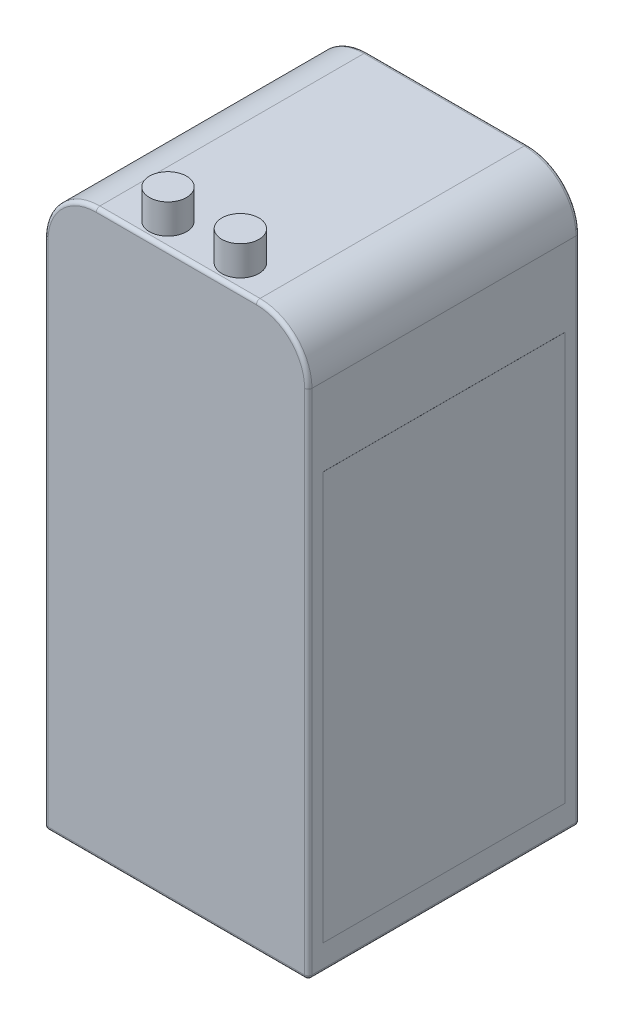
from build123d import *

# Parameters (mm, degrees)
SKETCH1_W             = 35.6
SKETCH1_H             = 36.6
BOSS_EXTRUDE1_DEPTH   = 76
SKETCH2_R             = 2.5
BOSS_EXTRUDE2_DEPTH   = 4
BOSS_EXTRUDE2_2_DEPTH = 4
FILLET1_R             = 7
FILLET2_R             = 0.5
SKETCH3_W             = 32.6
SKETCH3_H             = 55
BOSS_EXTRUDE3_DEPTH   = 0.01


with BuildPart() as part:
    # Sketch1 → Boss-Extrude1 (new body)
    with BuildSketch(Plane(origin=(0, 0, 0), x_dir=(1, 0, 0), z_dir=(0, 1, 0))):
        with Locations((17.8, 18.3)):
            Rectangle(SKETCH1_W, SKETCH1_H)
    extrude(amount=BOSS_EXTRUDE1_DEPTH)

    # Fillet1
    fillet1_edges = [part.edges().sort_by_distance(p)[0] for p in [
        (35.6, 76, -18.3),
        (0, 76, -18.3),
    ]]
    fillet(fillet1_edges, radius=FILLET1_R)

    # Fillet2
    fillet2_edges = [part.edges().sort_by_distance(p)[0] for p in [
        (17.8, 76, 0),
        (17.8, 76, -36.6),
        (35.6, 34.5, 0),
        (0, 34.5, 0),
        (33.549747468, 73.949747468, 0),
        (2.050252532, 73.949747468, 0),
        (0, 34.5, -36.6),
        (35.6, 34.5, -36.6),
        (33.549747468, 73.949747468, -36.6),
        (2.050252532, 73.949747468, -36.6),
        (17.8, 0, -36.6),
        (35.6, 0, -18.3),
        (17.8, 0, 0),
        (0, 0, -18.3),
    ]]
    fillet(fillet2_edges, radius=FILLET2_R)

    # Sketch3 → Boss-Extrude3 (add)
    with BuildSketch(Plane(origin=(35.6, 0, 0), x_dir=(0, 0, -1), z_dir=(1, 0, 0))):
        with Locations((18.3, 31)):
            Rectangle(SKETCH3_W, SKETCH3_H)
    extrude(amount=BOSS_EXTRUDE3_DEPTH)


with BuildPart() as body_2:
    # Sketch2 → Boss-Extrude2 (new body)
    with BuildSketch(Plane(origin=(0, 76, 0), x_dir=(1, 0, 0), z_dir=(0, 1, 0))):
        with Locations((13.354835188, 3.323329695)):
            Circle(SKETCH2_R)
    extrude(amount=BOSS_EXTRUDE2_DEPTH)


with BuildPart() as body_3:
    # Sketch2 → Boss-Extrude2 2 (new body)
    with BuildSketch(Plane(origin=(0, 76, 0), x_dir=(1, 0, 0), z_dir=(0, 1, 0))):
        with Locations((23.120727578, 3.323329695)):
            Circle(SKETCH2_R)
    extrude(amount=BOSS_EXTRUDE2_2_DEPTH)


solid = Compound([part.part, body_2.part, body_3.part])
